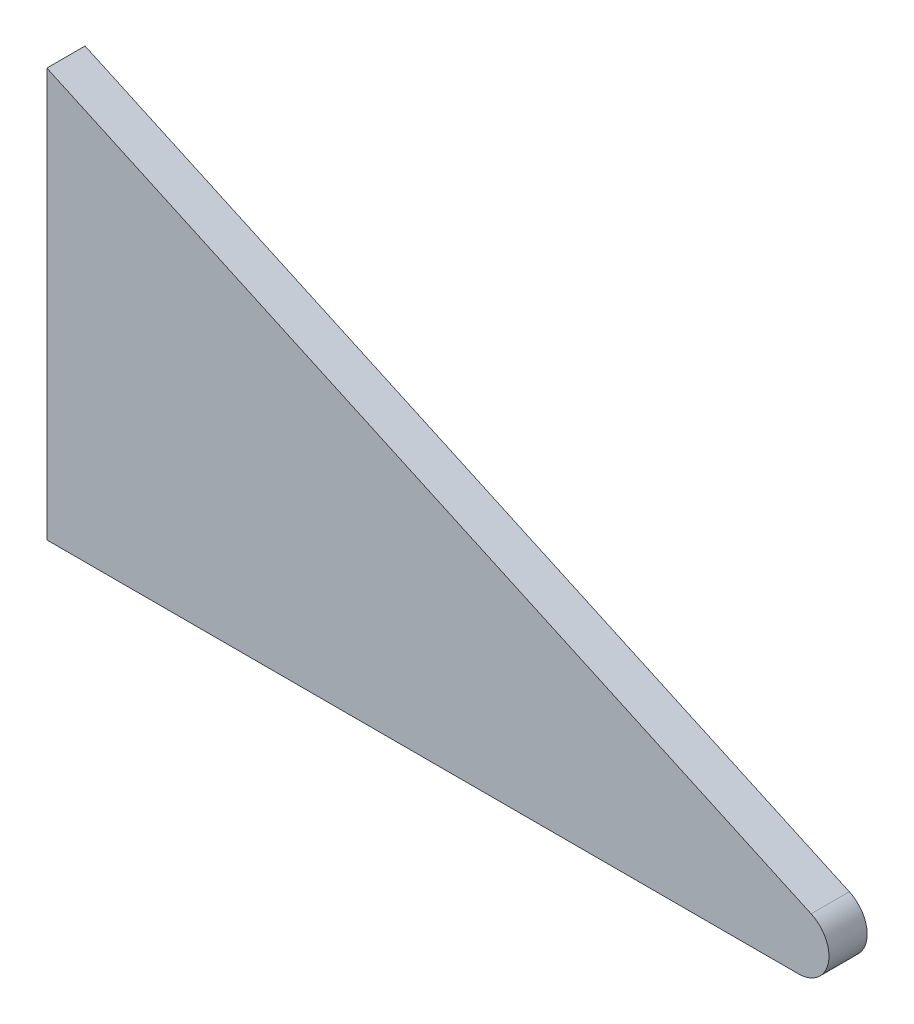
from build123d import *

# Parameters (mm, degrees)
EXTRUDE1_DEPTH = 3.175


with BuildPart() as part:
    # Sketch1 → Extrude1 (new body)
    with BuildSketch(Plane.XY):
        with BuildLine():
            Line((90.184030844, 0), (152.625697511, 0))
            ThreePointArc((152.625697511, 0), (155.107278383, 1.998376171), (153.684030844, 4.849010731))
            Line((153.684030844, 4.849010731), (90.184030844, 33.954188012))
            Line((90.184030844, 33.954188012), (90.184030844, 0))
        make_face()
    extrude(amount=EXTRUDE1_DEPTH)


solid = part.part
